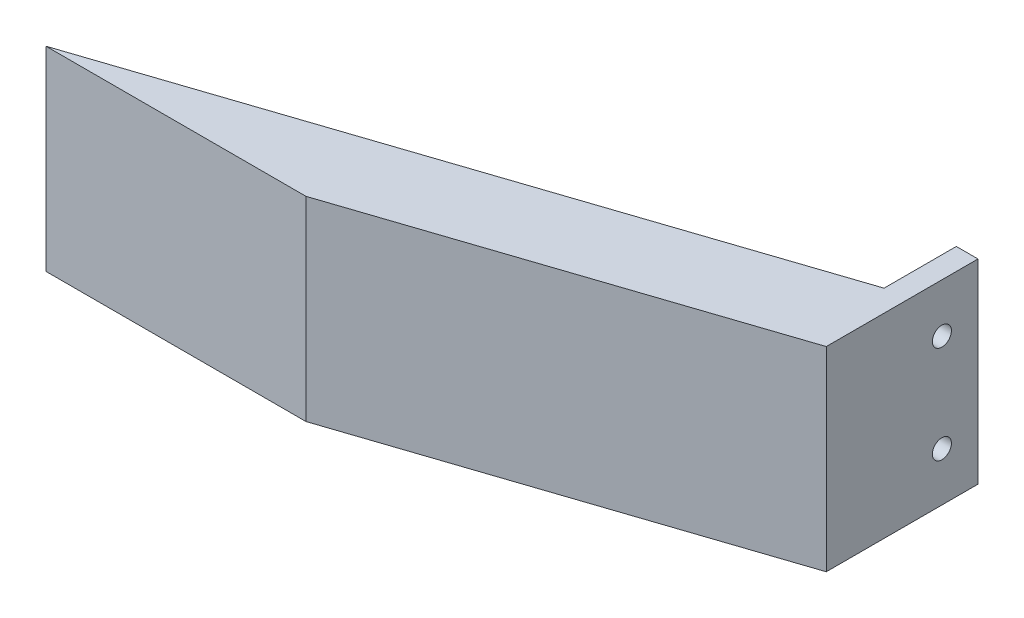
from build123d import *

# Parameters (mm, degrees)
BOSS_EXTRUDE1_DEPTH = 45
SKETCH2_W           = 35
SKETCH2_H           = 45
BOSS_EXTRUDE2_DEPTH = 5
SKETCH3_R           = 2.2
CUT_EXTRUDE1_DEPTH  = 5


with BuildPart() as part:
    # Sketch1 → Boss-Extrude1 (new body)
    with BuildSketch(Plane(origin=(0, 0, 0), x_dir=(1, 0, 0), z_dir=(0, 1, 0))):
        Polygon((150, 50), (0, 0), (59.974081308, 0), (150, 30), align=None)
    extrude(amount=BOSS_EXTRUDE1_DEPTH)

    # Sketch2 → Boss-Extrude2 (add)
    with BuildSketch(Plane(origin=(150, 0, 0), x_dir=(0, 0, -1), z_dir=(1, 0, 0))):
        with Locations((47.5, 22.5)):
            Rectangle(SKETCH2_W, SKETCH2_H)
    extrude(amount=-BOSS_EXTRUDE2_DEPTH)

    # Sketch3 → Cut-Extrude1 (cut)
    with BuildSketch(Plane.ZY.offset(-145)):
        with Locations((-56.666666667, 33.75)):
            Circle(SKETCH3_R)
        with Locations((-56.666666667, 11.25)):
            Circle(SKETCH3_R)
    extrude(amount=-CUT_EXTRUDE1_DEPTH, mode=Mode.SUBTRACT)


solid = part.part
